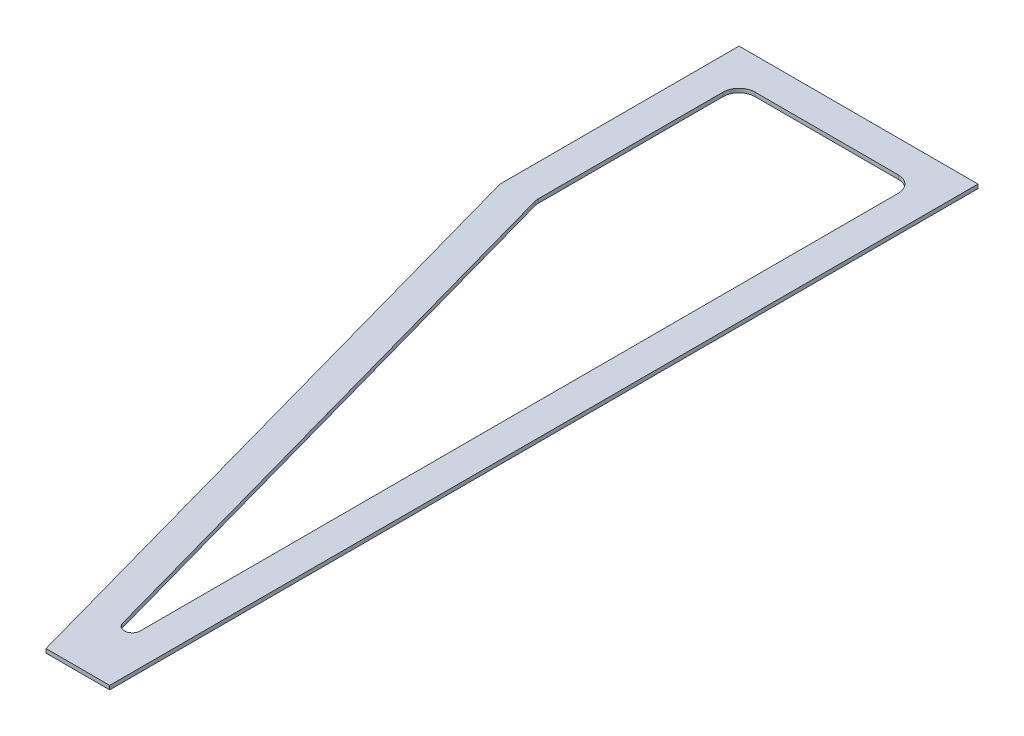
from build123d import *

# Parameters (mm, degrees)
BOSS_EXTRUDE1_DEPTH = 6.35


with BuildPart() as part:
    # Sketch1 → Boss-Extrude1 (new body)
    with BuildSketch(Plane(origin=(0, 0, 0), x_dir=(1, 0, 0), z_dir=(0, 1, 0))):
        Polygon((0, 0), (0, -1384.3), (-101.6, -1384.3), (-381, -381), (-381, 0), align=None)
        with BuildLine():
            Line((-329.268912254, -377.402099424), (-75.377865092, -1289.10176878))
            ThreePointArc((-75.377865092, -1289.10176878), (-61.858495332, -1297.3737261), (-50.8, -1286.019946218))
            Line((-50.8, -1286.019946218), (-50.8, -76.2))
            ThreePointArc((-50.8, -76.2), (-58.239487758, -58.239487758), (-76.2, -50.8))
            Line((-76.2, -50.8), (-304.8, -50.8))
            ThreePointArc((-304.8, -50.8), (-322.760512242, -58.239487758), (-330.2, -76.2))
            Line((-330.2, -76.2), (-330.2, -370.58797196))
            ThreePointArc((-330.2, -370.58797196), (-329.966151586, -374.026694742), (-329.268912254, -377.402099424))
        make_face(mode=Mode.SUBTRACT)
    extrude(amount=BOSS_EXTRUDE1_DEPTH)


solid = part.part
